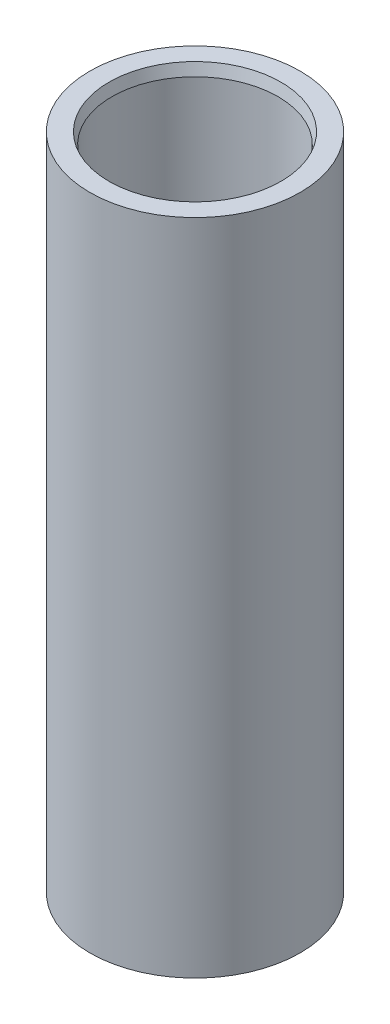
from build123d import *

# Parameters (mm, degrees)
SKETCH1_R          = 38
EXTRUDE1_DEPTH     = 238
SKETCH2_R          = 30
CUT_EXTRUDE1_DEPTH = 239
CHAMFER1_SIZE      = 4
CHAMFER1_SIZE2     = 1.07179677
CHAMFER2_SIZE      = 4
CHAMFER2_SIZE2     = 1.07179677


with BuildPart() as part:
    # Sketch1 → Extrude1 (new body)
    with BuildSketch(Plane(origin=(0, 0, 0), x_dir=(1, 0, 0), z_dir=(0, 1, 0))):
        Circle(SKETCH1_R)
    extrude(amount=EXTRUDE1_DEPTH)

    # Sketch2 → Cut-Extrude1 (cut, through all)
    with BuildSketch(Plane(origin=(0, 238, 0), x_dir=(-1, 0, 0), z_dir=(0, 1, 0))):
        Circle(SKETCH2_R)
    extrude(amount=-CUT_EXTRUDE1_DEPTH, mode=Mode.SUBTRACT)

    # Chamfer1
    chamfer1_edges = [part.edges().sort_by_distance(p)[0] for p in [
        (30, 0, 0),
    ]]
    chamfer1_side = [part.faces().sort_by_distance(p)[0] for p in [
        (30, 119, 0),
    ]]
    chamfer(chamfer1_edges, length=CHAMFER1_SIZE, length2=CHAMFER1_SIZE2, reference=chamfer1_side[0])

    # Chamfer2
    chamfer2_edges = [part.edges().sort_by_distance(p)[0] for p in [
        (30, 238, 0),
    ]]
    chamfer2_side = [part.faces().sort_by_distance(p)[0] for p in [
        (30, 121, 0),
    ]]
    chamfer(chamfer2_edges, length=CHAMFER2_SIZE, length2=CHAMFER2_SIZE2, reference=chamfer2_side[0])


solid = part.part
